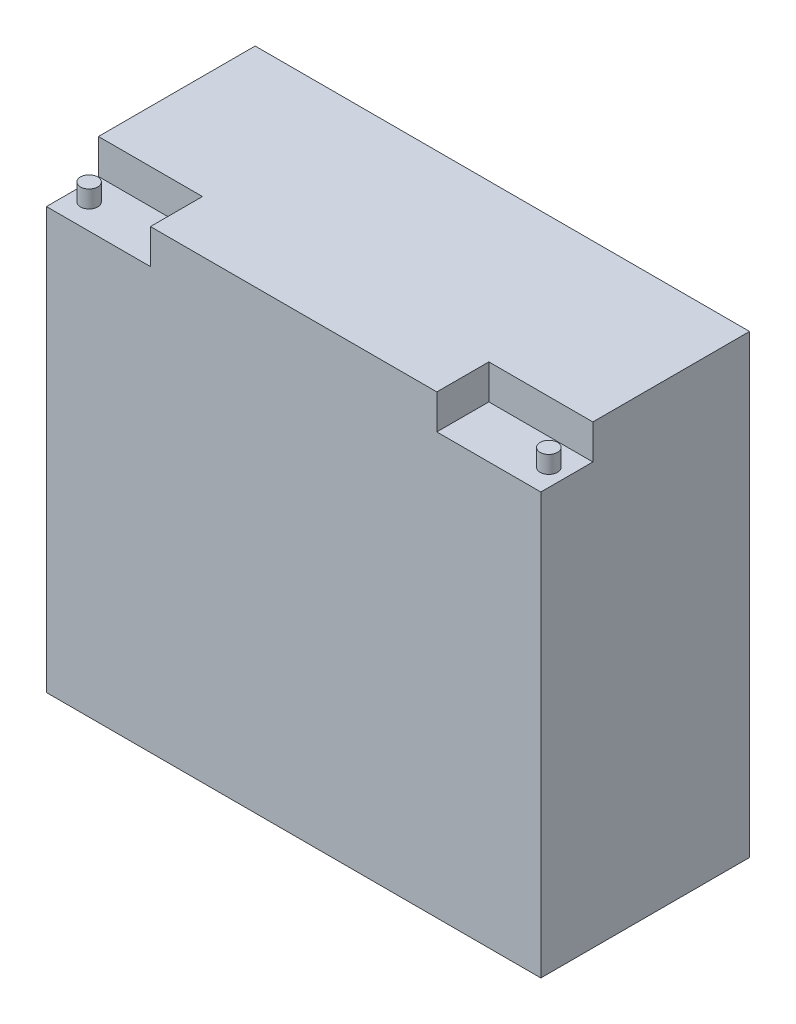
from build123d import *

# Parameters (mm, degrees)
SKETCH1_W           = 181.102
SKETCH1_H           = 76.454
BOSS_EXTRUDE1_DEPTH = 166.878
SKETCH2_W           = 38.1
SKETCH2_H           = 19.05
CUT_EXTRUDE1_DEPTH  = 12.7
SKETCH3_R           = 3.175
BOSS_EXTRUDE2_DEPTH = 6.35


with BuildPart() as part:
    # Sketch1 → Boss-Extrude1 (new body)
    with BuildSketch(Plane(origin=(0, 0, 0), x_dir=(1, 0, 0), z_dir=(0, 1, 0))):
        with Locations((-20.72278737, -46.488845277)):
            Rectangle(SKETCH1_W, SKETCH1_H)
    extrude(amount=BOSS_EXTRUDE1_DEPTH)

    # Sketch2 → Cut-Extrude1 (cut)
    with BuildSketch(Plane(origin=(0, 166.878, 0), x_dir=(1, 0, 0), z_dir=(0, 1, 0))):
        with Locations((-92.22378737, -75.190845277)):
            Rectangle(SKETCH2_W, SKETCH2_H)
        with Locations((50.77821263, -75.190845277)):
            Rectangle(SKETCH2_W, SKETCH2_H)
    extrude(amount=-CUT_EXTRUDE1_DEPTH, mode=Mode.SUBTRACT)

    # Sketch3 → Boss-Extrude2 (add)
    with BuildSketch(Plane(origin=(0, 154.178, 0), x_dir=(1, 0, 0), z_dir=(0, 1, 0))):
        with Locations((63.47821263, -75.443767272)):
            Circle(SKETCH3_R)
        with Locations((-104.92378737, -75.443767272)):
            Circle(SKETCH3_R)
    extrude(amount=BOSS_EXTRUDE2_DEPTH)


solid = part.part
